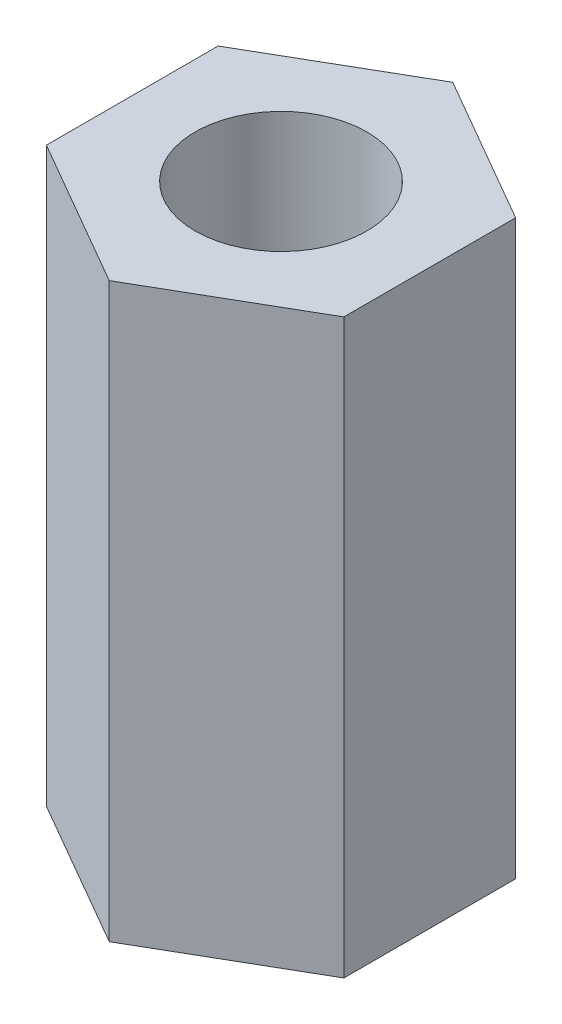
from build123d import *

# Parameters (mm, degrees)
ESQUISSE1_R      = 1.5
EXTRUSION1_DEPTH = 10


with BuildPart() as part:
    # Esquisse1 → Extrusion1 (new body)
    with BuildSketch(Plane(origin=(0, 0, 0), x_dir=(1, 0, 0), z_dir=(0, 1, 0))):
        Polygon((0, 3), (-2.598076211, 1.5), (-2.598076211, -1.5), (0, -3), (2.598076211, -1.5), (2.598076211, 1.5), align=None)
        Circle(ESQUISSE1_R, mode=Mode.SUBTRACT)
    extrude(amount=EXTRUSION1_DEPTH)


solid = part.part
